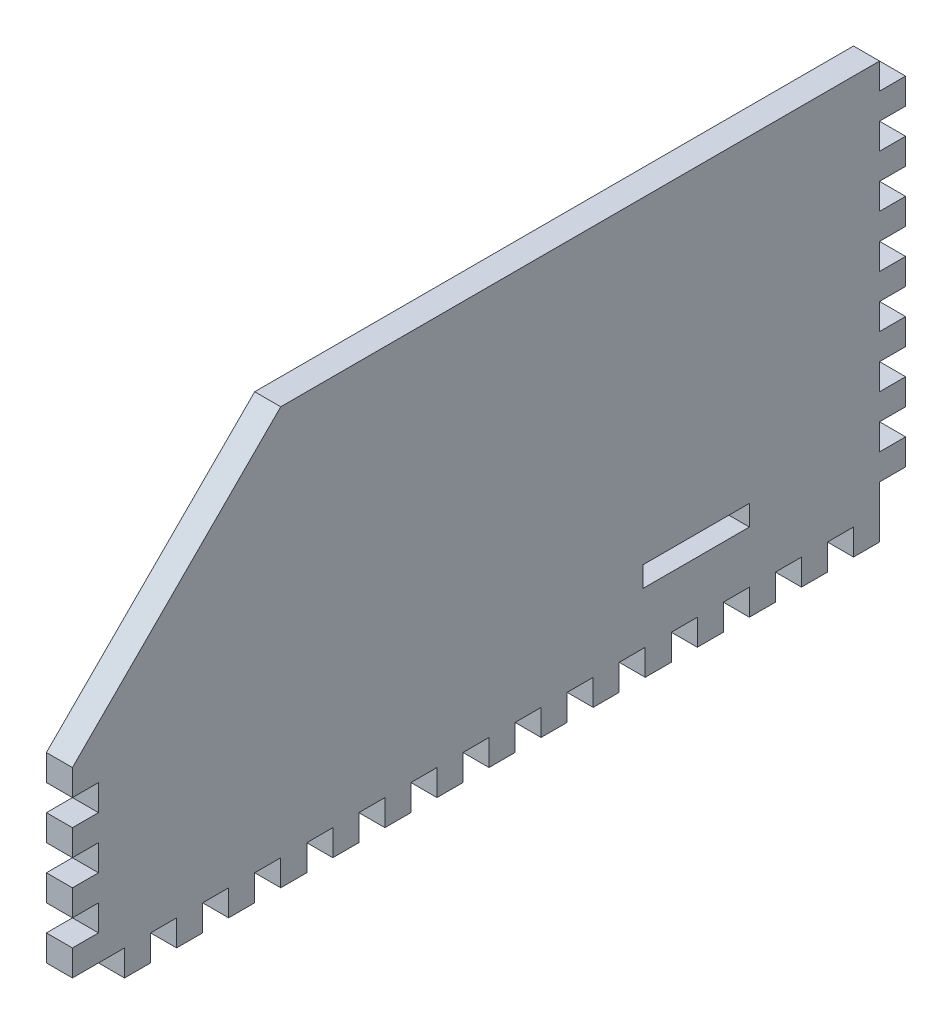
from build123d import *

# Parameters (mm, degrees)
SKETCH1_W           = 203.2
SKETCH1_H           = 101.6
BOSS_EXTRUDE1_DEPTH = 6.35
SKETCH2_W           = 6.35
SKETCH2_H           = 12.7
CUT_EXTRUDE1_DEPTH  = 6.35
SKETCH5_W           = 6.35
SKETCH5_H           = 6.35
CUT_EXTRUDE3_DEPTH  = 6.35
LPATTERN1_COUNT     = 15
LPATTERN1_PITCH     = 12.7
SKETCH6_W           = 6.35
SKETCH6_H           = 6.35
CUT_EXTRUDE4_DEPTH  = 6.35
SKETCH7_W           = 6.35
SKETCH7_H           = 6.35
CUT_EXTRUDE5_DEPTH  = 6.35
LPATTERN2_COUNT     = 7
LPATTERN2_PITCH     = 12.7
CUT_EXTRUDE6_DEPTH  = 6.35
SKETCH9_W           = 6.35
SKETCH9_H           = 6.35
CUT_EXTRUDE7_DEPTH  = 6.35
LPATTERN3_COUNT     = 3
LPATTERN3_PITCH     = 12.7
SKETCH10_W          = 25.9
SKETCH10_H          = 5
CUT_EXTRUDE8_DEPTH  = 6.35


with BuildPart() as part:
    # Sketch1 → Boss-Extrude1 (new body)
    with BuildSketch(Plane(origin=(0, 0, 0), x_dir=(0, 0, -1), z_dir=(1, 0, 0))):
        with Locations((101.6, 50.8)):
            Rectangle(SKETCH1_W, SKETCH1_H)
    extrude(amount=BOSS_EXTRUDE1_DEPTH)

    # Sketch2 → Cut-Extrude1 (cut)
    with BuildSketch(Plane.XZ):
        with Locations((3.175, -6.35)):
            Rectangle(SKETCH2_W, SKETCH2_H)
    extrude(amount=-CUT_EXTRUDE1_DEPTH, mode=Mode.SUBTRACT)

    # Sketch5 → Cut-Extrude3 (cut)
    with BuildSketch(Plane.XZ):
        with Locations((3.175, -22.225)):
            Rectangle(SKETCH5_W, SKETCH5_H)
    cut_extrude3 = extrude(amount=-CUT_EXTRUDE3_DEPTH, mode=Mode.SUBTRACT)

    # LPattern1: Cut-Extrude3 ×15
    with Locations(*[(0, 0, -i * LPATTERN1_PITCH) for i in range(1, LPATTERN1_COUNT)]):
        add(cut_extrude3, mode=Mode.SUBTRACT)

    # Sketch6 → Cut-Extrude4 (cut)
    with BuildSketch(Plane(origin=(0, 0, -203.2), x_dir=(-1, 0, 0), z_dir=(0, 0, -1))):
        with Locations((-3.175, 9.525)):
            Rectangle(SKETCH6_W, SKETCH6_H)
    extrude(amount=-CUT_EXTRUDE4_DEPTH, mode=Mode.SUBTRACT)

    # Sketch7 → Cut-Extrude5 (cut)
    with BuildSketch(Plane(origin=(0, 0, -203.2), x_dir=(-1, 0, 0), z_dir=(0, 0, -1))):
        with Locations((-3.175, 22.225)):
            Rectangle(SKETCH7_W, SKETCH7_H)
    cut_extrude5 = extrude(amount=-CUT_EXTRUDE5_DEPTH, mode=Mode.SUBTRACT)

    # LPattern2: Cut-Extrude5 ×7
    with Locations(*[(0, i * LPATTERN2_PITCH, 0) for i in range(1, LPATTERN2_COUNT)]):
        add(cut_extrude5, mode=Mode.SUBTRACT)

    # Sketch8 → Cut-Extrude6 (cut)
    with BuildSketch(Plane(origin=(6.35, 0, 0), x_dir=(0, 0, -1), z_dir=(1, 0, 0))):
        Polygon((0, 101.6), (50.8, 101.6), (0, 50.8), align=None)
    extrude(amount=-CUT_EXTRUDE6_DEPTH, mode=Mode.SUBTRACT)

    # Sketch9 → Cut-Extrude7 (cut)
    with BuildSketch(Plane.XY):
        with Locations((3.175, 15.875)):
            Rectangle(SKETCH9_W, SKETCH9_H)
    cut_extrude7 = extrude(amount=-CUT_EXTRUDE7_DEPTH, mode=Mode.SUBTRACT)

    # LPattern3: Cut-Extrude7 ×3
    with Locations(*[(0, i * LPATTERN3_PITCH, 0) for i in range(1, LPATTERN3_COUNT)]):
        add(cut_extrude7, mode=Mode.SUBTRACT)

    # Sketch10 → Cut-Extrude8 (cut)
    with BuildSketch(Plane(origin=(6.35, 0, 0), x_dir=(0, 0, -1), z_dir=(1, 0, 0))):
        with Locations((152.15, 21.55)):
            Rectangle(SKETCH10_W, SKETCH10_H)
    extrude(amount=-CUT_EXTRUDE8_DEPTH, mode=Mode.SUBTRACT)


solid = part.part
